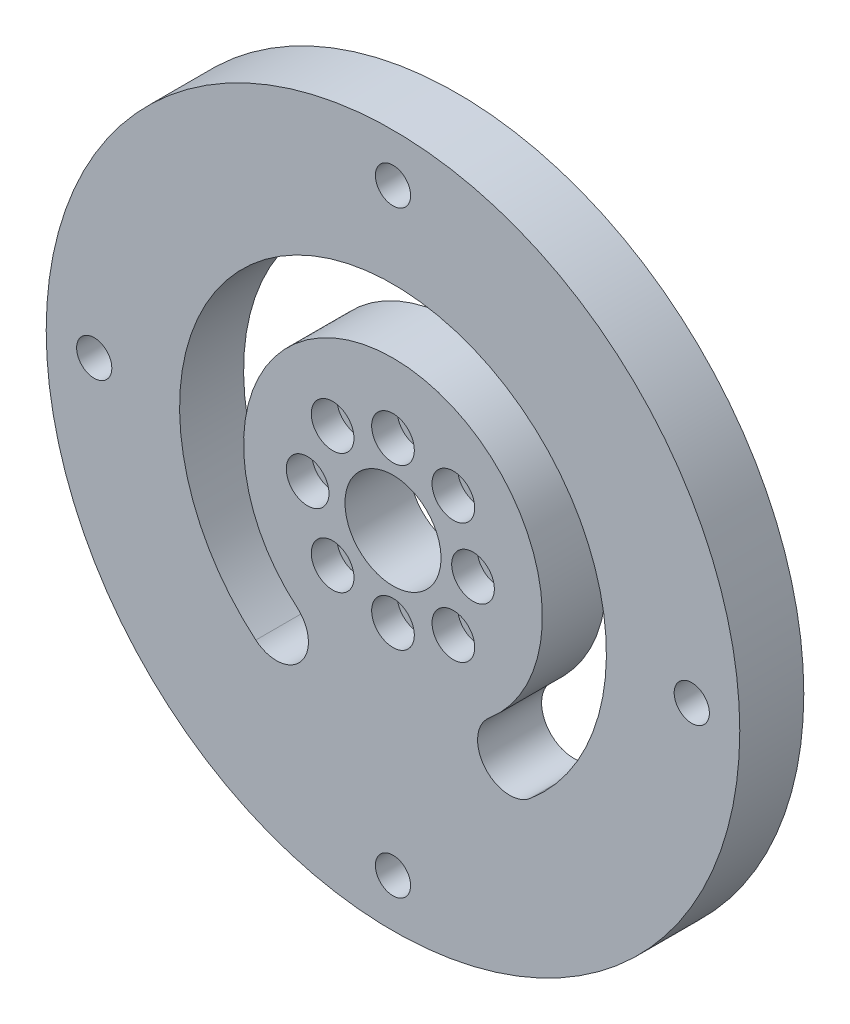
from build123d import *

# Parameters (mm, degrees)
SKETCH1_R           = 32.5
BOSS_EXTRUDE1_DEPTH = 6
SKETCH16_R          = 1
CUT_EXTRUDE8_DEPTH  = 7
SKETCH17_R          = 2
CUT_EXTRUDE9_DEPTH  = 2.4
SKETCH18_R          = 4.5
CUT_EXTRUDE10_DEPTH = 7
SKETCH19_R          = 1.65
CUT_EXTRUDE11_DEPTH = 10
CUT_EXTRUDE12_DEPTH = 3
CUT_EXTRUDE13_DEPTH = 7


with BuildPart() as part:
    # Sketch1 → Boss-Extrude1 (new body)
    with BuildSketch(Plane.XY):
        Circle(SKETCH1_R)
    extrude(amount=BOSS_EXTRUDE1_DEPTH)

    # Sketch16 → Cut-Extrude8 (cut, through all)
    with BuildSketch(Plane.XY.offset(6)):
        with Locations((-8, 0)):
            Circle(SKETCH16_R)
        with Locations((-5.656854249, 5.656854249)):
            Circle(SKETCH16_R)
        with Locations((0, 8)):
            Circle(SKETCH16_R)
        with Locations((5.656854249, 5.656854249)):
            Circle(SKETCH16_R)
        with Locations((8, 0)):
            Circle(SKETCH16_R)
        with Locations((5.656854249, -5.656854249)):
            Circle(SKETCH16_R)
        with Locations((0, -8)):
            Circle(SKETCH16_R)
        with Locations((-5.656854249, -5.656854249)):
            Circle(SKETCH16_R)
    extrude(amount=-CUT_EXTRUDE8_DEPTH, mode=Mode.SUBTRACT)

    # Sketch17 → Cut-Extrude9 (cut)
    with BuildSketch(Plane.XY.offset(6)):
        with Locations((7.5, 0)):
            Circle(SKETCH17_R)
        with Locations((-8, 0)):
            Circle(SKETCH17_R)
        with Locations((0, -7.5)):
            Circle(SKETCH17_R)
        with Locations((0, 7.5)):
            Circle(SKETCH17_R)
        with Locations((-5.656854249, 5.656854249)):
            Circle(SKETCH17_R)
        with Locations((5.656854249, 5.656854249)):
            Circle(SKETCH17_R)
        with Locations((5.656854249, -5.656854249)):
            Circle(SKETCH17_R)
        with Locations((-5.656854249, -5.656854249)):
            Circle(SKETCH17_R)
    extrude(amount=-CUT_EXTRUDE9_DEPTH, mode=Mode.SUBTRACT)

    # Sketch18 → Cut-Extrude10 (cut, through all)
    with BuildSketch(Plane(origin=(0, 0, 0), x_dir=(-1, 0, 0), z_dir=(0, 0, -1))):
        Circle(SKETCH18_R)
    extrude(amount=-CUT_EXTRUDE10_DEPTH, mode=Mode.SUBTRACT)

    # Sketch19 → Cut-Extrude11 (cut)
    with BuildSketch(Plane.XY.offset(6)):
        with Locations((0, 28)):
            Circle(SKETCH19_R)
        with Locations((28, 0)):
            Circle(SKETCH19_R)
        with Locations((0, -28)):
            Circle(SKETCH19_R)
        with Locations((-28, 0)):
            Circle(SKETCH19_R)
    extrude(amount=-CUT_EXTRUDE11_DEPTH, mode=Mode.SUBTRACT)

    # Sketch20 → Cut-Extrude12 (cut)
    with BuildSketch(Plane(origin=(0, 0, 0), x_dir=(-1, 0, 0), z_dir=(0, 0, -1))):
        Polygon((1.616580754, 30.8), (-1.616580754, 30.8), (-3.233161507, 28), (-1.616580754, 25.2), (1.616580754, 25.2), (3.233161507, 28), align=None)
        Polygon((29.616580754, 2.8), (26.383419246, 2.8), (24.766838493, 0), (26.383419246, -2.8), (29.616580754, -2.8), (31.233161507, 0), align=None)
        Polygon((1.616580754, -25.2), (-1.616580754, -25.2), (-3.233161507, -28), (-1.616580754, -30.8), (1.616580754, -30.8), (3.233161507, -28), align=None)
        Polygon((-26.383419246, 2.8), (-29.616580754, 2.8), (-31.233161507, 0), (-29.616580754, -2.8), (-26.383419246, -2.8), (-24.766838493, 0), align=None)
    extrude(amount=-CUT_EXTRUDE12_DEPTH, mode=Mode.SUBTRACT)

    # Sketch21 → Cut-Extrude13 (cut, through all)
    with BuildSketch(Plane.XY.offset(6)):
        with BuildLine():
            ThreePointArc((12.855752194, -15.320888862), (0, 20), (-12.855752194, -15.320888862))
            ThreePointArc((-12.855752194, -15.320888862), (-8.629256035, -14.951118362), (-8.999026536, -10.724622204))
            ThreePointArc((-8.999026536, -10.724622204), (0, 14), (8.999026536, -10.724622204))
            ThreePointArc((8.999026536, -10.724622204), (8.629256035, -14.951118362), (12.855752194, -15.320888862))
        make_face()
    extrude(amount=-CUT_EXTRUDE13_DEPTH, mode=Mode.SUBTRACT)


solid = part.part
